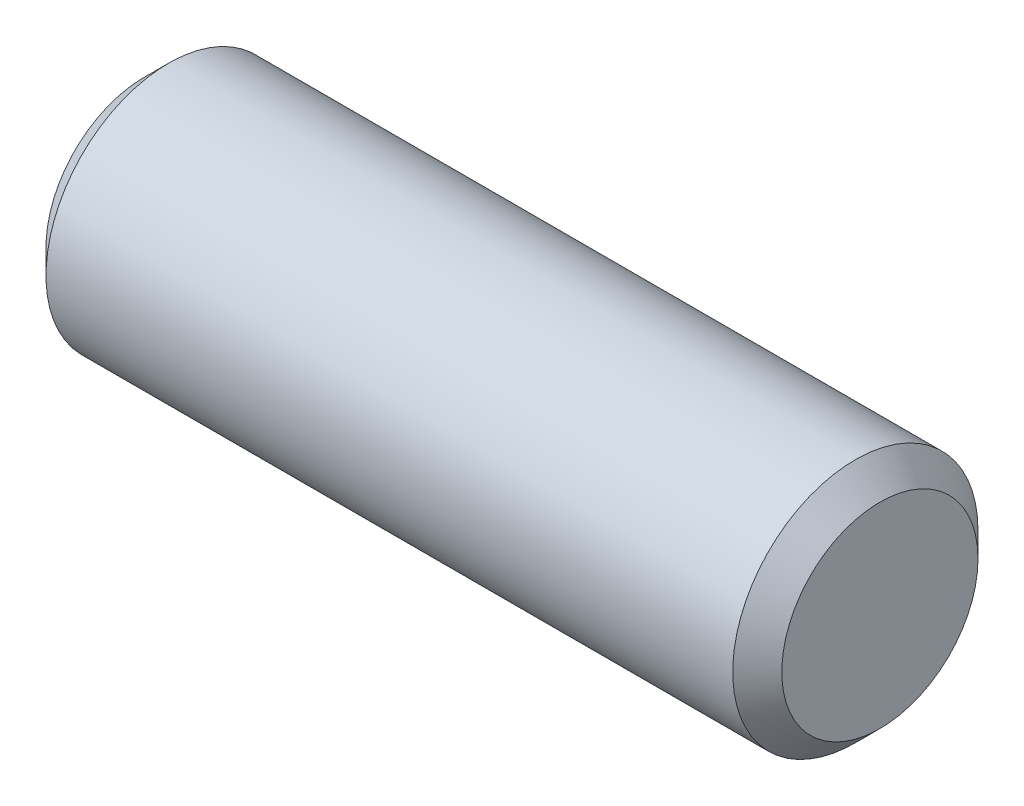
from build123d import *

# Parameters (mm, degrees)
SKETCH2_R           = 1.5875
EXTRUDE1_DEPTH      = 4.7625
EXTRUDE1_DEPTH_BACK = 4.7625
CHAMFER1_SIZE       = 0.3175


with BuildPart() as part:
    # Sketch2 → Extrude1 (new body, two sides)
    with BuildSketch(Plane(origin=(0, 0, 0), x_dir=(0, 0, -1), z_dir=(1, 0, 0))) as extrude1_sk:
        Circle(SKETCH2_R)
    extrude(amount=EXTRUDE1_DEPTH)
    extrude(extrude1_sk.sketch, amount=-EXTRUDE1_DEPTH_BACK)

    # Chamfer1
    chamfer1_edges = [part.edges().sort_by_distance(p)[0] for p in [
        (-4.7625, 0, 1.5875),
        (4.7625, 0, 1.5875),
    ]]
    chamfer(chamfer1_edges, length=CHAMFER1_SIZE)


solid = part.part
